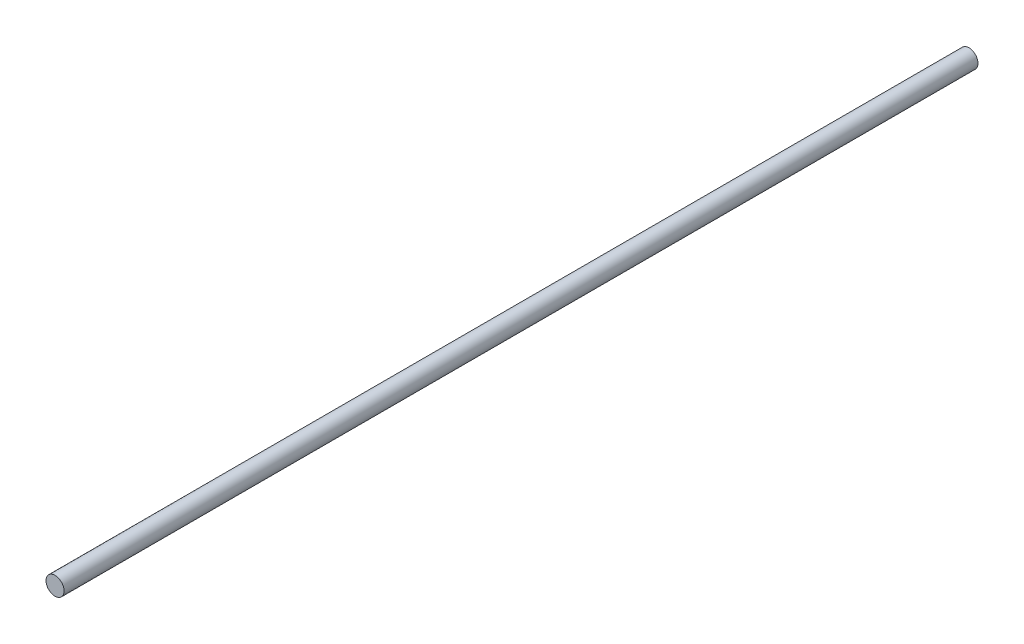
from build123d import *

# Parameters (mm, degrees)
SKETCH1_R           = 2
BOSS_EXTRUDE1_DEPTH = 201.85


with BuildPart() as part:
    # Sketch1 → Boss-Extrude1 (new body)
    with BuildSketch(Plane.XY):
        Circle(SKETCH1_R)
    extrude(amount=BOSS_EXTRUDE1_DEPTH)


solid = part.part
